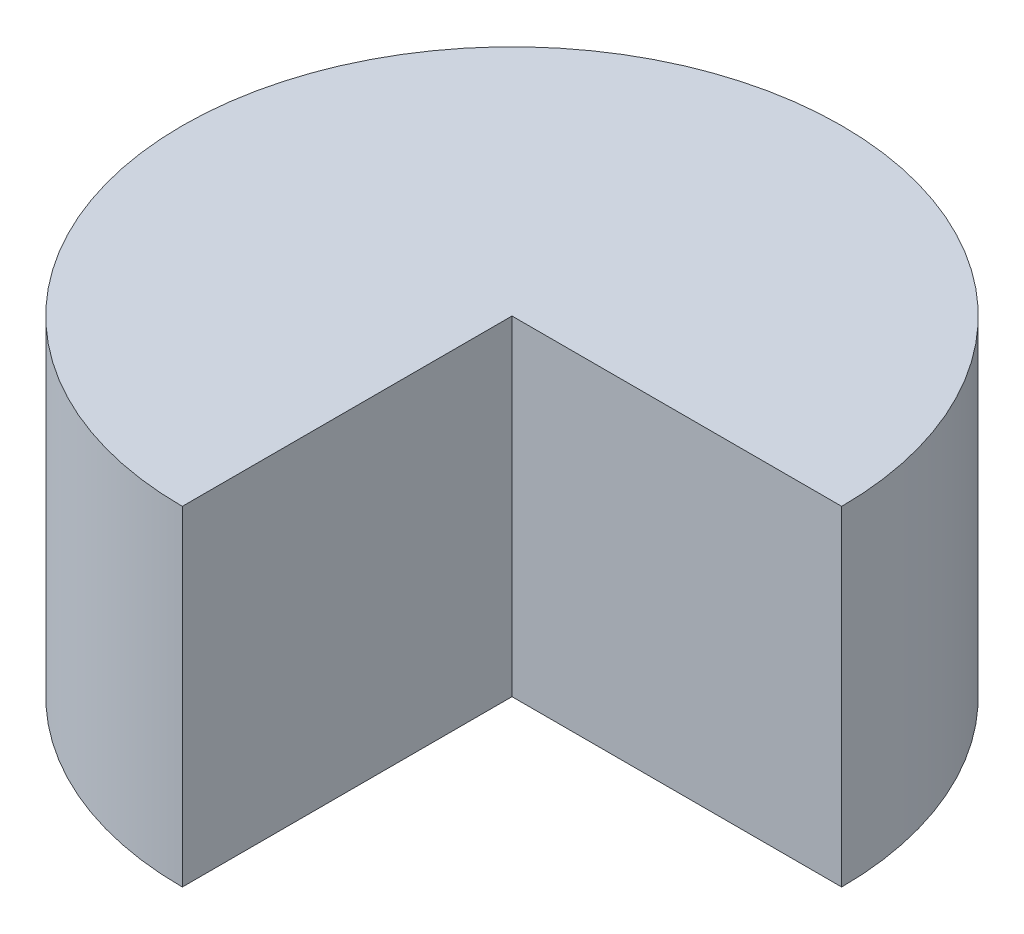
from build123d import *

# Parameters (mm, degrees)
BOSS_EXTRUDE1_DEPTH = 80


with BuildPart() as part:
    # Sketch1 → Boss-Extrude1 (new body)
    with BuildSketch(Plane(origin=(0, 0, 0), x_dir=(1, 0, 0), z_dir=(0, 1, 0))):
        with BuildLine():
            Line((0, 0), (80, 0))
            ThreePointArc((80, 0), (-56.568542495, 56.568542495), (0, -80))
            Line((0, -80), (0, 0))
        make_face()
    extrude(amount=BOSS_EXTRUDE1_DEPTH)


solid = part.part
